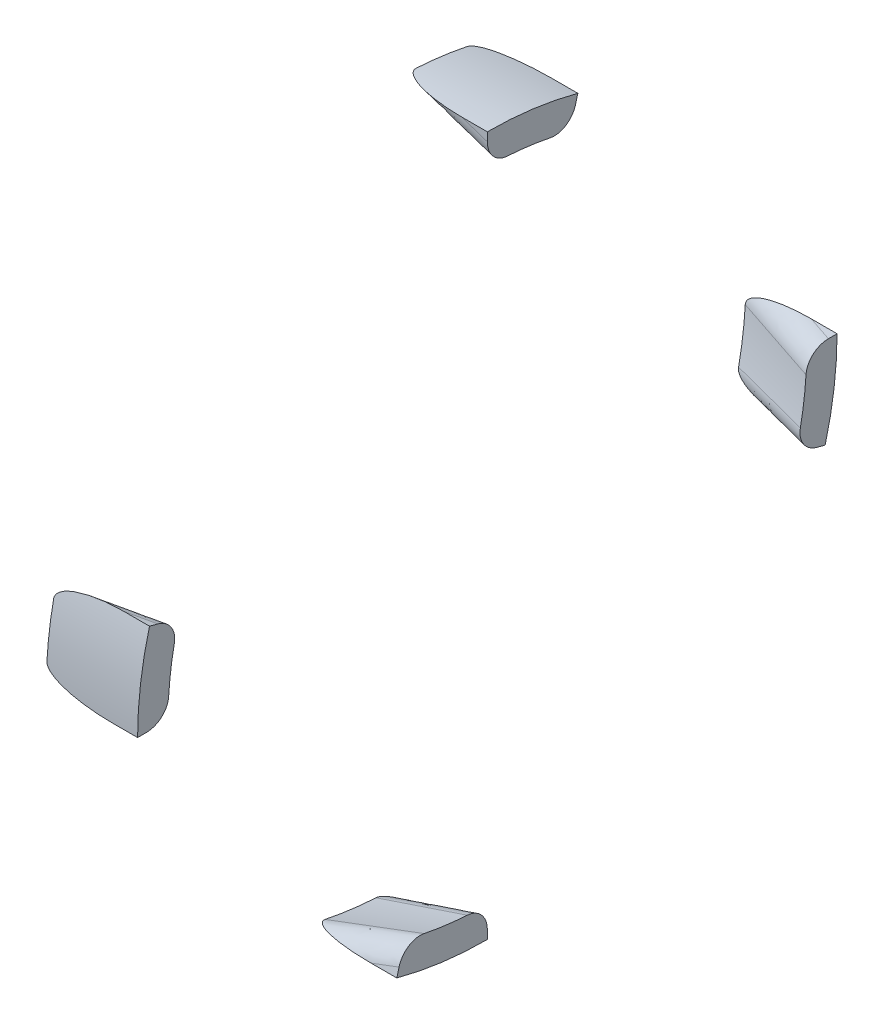
from build123d import *

# Parameters (mm, degrees)
REVOLVE1_ANGLE    = 15
CIRPATTERN1_COUNT = 4
FILLET1_R         = 8.89
FILLET2_R         = 8.89
FILLET3_R         = 8.89
FILLET4_R         = 8.89


with BuildPart() as part:
    # Sketch1 → Revolve1 (revolve)
    with BuildSketch(Plane.XY):
        Polygon((0, 0), (-38.1, 0), (0, -12.7), align=None)
    revolve(axis=Axis((0, -146.05, 0), (-1, 0, 0)), revolution_arc=REVOLVE1_ANGLE)


with BuildPart() as cirpattern1_1:
    # CirPattern1: pattern copy
    add(part.part.rotate(Axis((0, -146.05, 0), (-1, 0, 0)), 1 * 360 / CIRPATTERN1_COUNT))

    # Fillet4
    fillet4_edges = [cirpattern1_1.edges().sort_by_distance(p)[0] for p in [
        (-19.05, -182.207020601, -134.939837933),
        (-19.05, -146.05, -139.7),
    ]]
    fillet(fillet4_edges, radius=FILLET4_R)


with BuildPart() as cirpattern1_2:
    # CirPattern1: pattern copy
    add(part.part.rotate(Axis((0, -146.05, 0), (-1, 0, 0)), 2 * 360 / CIRPATTERN1_COUNT))

    # Fillet3
    fillet3_edges = [cirpattern1_2.edges().sort_by_distance(p)[0] for p in [
        (-19.05, -280.989837933, 36.157020601),
        (-19.05, -285.75, 0),
    ]]
    fillet(fillet3_edges, radius=FILLET3_R)


with BuildPart() as cirpattern1_3:
    # CirPattern1: pattern copy
    add(part.part.rotate(Axis((0, -146.05, 0), (-1, 0, 0)), 3 * 360 / CIRPATTERN1_COUNT))

    # Fillet2
    fillet2_edges = [cirpattern1_3.edges().sort_by_distance(p)[0] for p in [
        (-19.05, -109.892979399, 134.939837933),
        (-19.05, -146.05, 139.7),
    ]]
    fillet(fillet2_edges, radius=FILLET2_R)


with BuildPart() as part_1:
    add(part.part)

    # Fillet1
    fillet1_edges = [part_1.edges().sort_by_distance(p)[0] for p in [
        (-19.05, -11.110162067, -36.157020601),
        (-19.05, -6.35, 0),
    ]]
    fillet(fillet1_edges, radius=FILLET1_R)


solid = Compound([cirpattern1_1.part, cirpattern1_2.part, cirpattern1_3.part, part_1.part])
